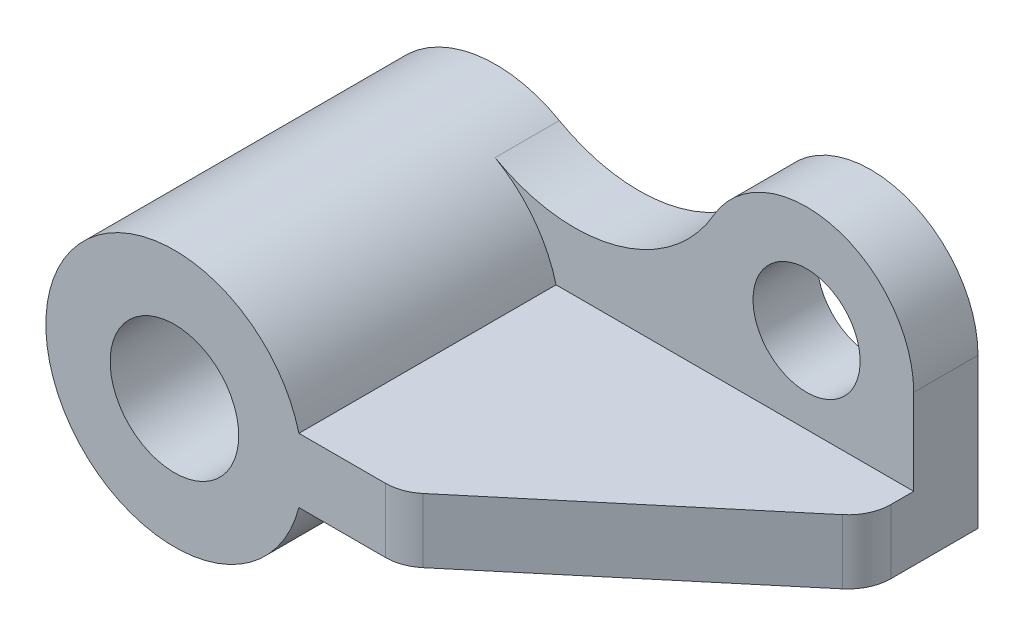
from build123d import *

# Parameters (mm, degrees)
SKETCH1_R           = 30
BOSS_EXTRUDE1_DEPTH = 75
SKETCH2_R           = 25
BOSS_EXTRUDE2_DEPTH = 30
CUT_EXTRUDE1_DEPTH  = 76
FILLET1_R           = 20


with BuildPart() as part:
    # Sketch1 → Boss-Extrude1 (new body, symmetric)
    with BuildSketch(Plane.XY):
        with BuildLine():
            Line((58.094750193, 15), (225, 15))
            Line((225, 15), (225, -15))
            Line((225, -15), (58.094750193, -15))
            ThreePointArc((58.094750193, -15), (-60, 0), (58.094750193, 15))
        make_face()
        Circle(SKETCH1_R, mode=Mode.SUBTRACT)
    extrude(amount=BOSS_EXTRUDE1_DEPTH, both=True)

    # Sketch2 → Boss-Extrude2 (add)
    with BuildSketch(Plane(origin=(0, 0, -75), x_dir=(-1, 0, 0), z_dir=(0, 0, -1))):
        with BuildLine():
            Line((-225, 15), (-225, 55))
            ThreePointArc((-225, 55), (-187.914926762, 103.30325731), (-131.671813331, 79.953321221))
            ThreePointArc((-131.671813331, 79.953321221), (-86.383524737, 45.01789196), (-29.635348145, 52.170356912))
            ThreePointArc((-29.635348145, 52.170356912), (-47.639808951, 36.475314984), (-58.094750193, 15))
            Line((-58.094750193, 15), (-225, 15))
        make_face()
        with Locations((-175, 55)):
            Circle(SKETCH2_R, mode=Mode.SUBTRACT)
    extrude(amount=-BOSS_EXTRUDE2_DEPTH)

    # Sketch3 → Cut-Extrude1 (cut, through all)
    with BuildSketch(Plane(origin=(0, 15, 0), x_dir=(1, 0, 0), z_dir=(0, 1, 0))):
        Polygon((225, 25), (105.824640741, -75), (225, -75), align=None)
    extrude(amount=-CUT_EXTRUDE1_DEPTH, mode=Mode.SUBTRACT)

    # Fillet1
    fillet1_edges = [part.edges().sort_by_distance(p)[0] for p in [
        (225, 0, -25),
        (105.824640741, 0, 75),
    ]]
    fillet(fillet1_edges, radius=FILLET1_R)


solid = part.part
